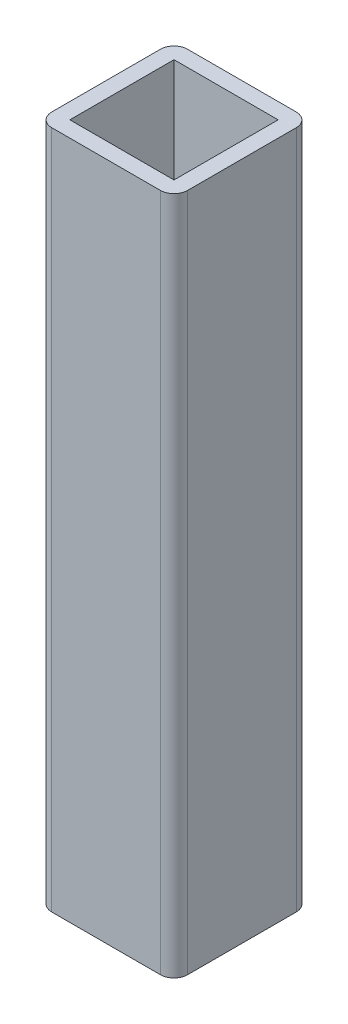
from build123d import *

# Parameters (mm, degrees)
SKETCH1_W           = 23
SKETCH1_H           = 23
BOSS_EXTRUDE1_DEPTH = 150


with BuildPart() as part:
    # Sketch1 → Boss-Extrude1 (new body)
    with BuildSketch(Plane(origin=(0, 0, 0), x_dir=(1, 0, 0), z_dir=(0, 1, 0))):
        with BuildLine():
            Line((12, 15), (-12, 15))
            ThreePointArc((-12, 15), (-14.121320344, 14.121320344), (-15, 12))
            Line((-15, 12), (-15, -12))
            ThreePointArc((-15, -12), (-14.121320344, -14.121320344), (-12, -15))
            Line((-12, -15), (12, -15))
            ThreePointArc((12, -15), (14.121320344, -14.121320344), (15, -12))
            Line((15, -12), (15, 12))
            ThreePointArc((15, 12), (14.121320344, 14.121320344), (12, 15))
        make_face()
        Rectangle(SKETCH1_W, SKETCH1_H, mode=Mode.SUBTRACT)
    extrude(amount=BOSS_EXTRUDE1_DEPTH)


solid = part.part
